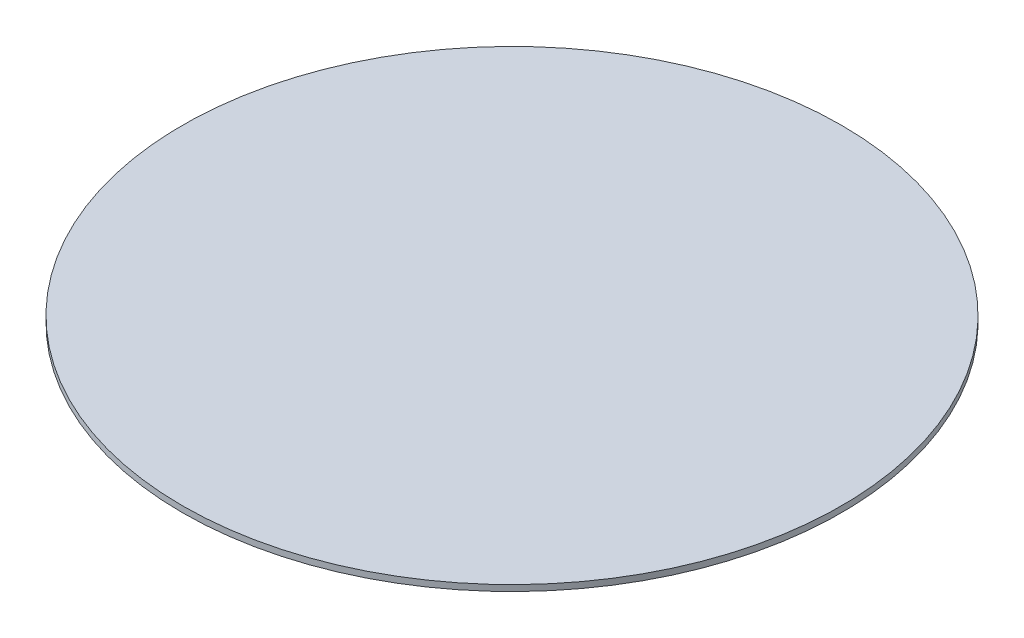
from build123d import *

# Parameters (mm, degrees)
ESQUISSE1_R        = 60
BOSS_EXTRU_1_DEPTH = 1.1


with BuildPart() as part:
    # Esquisse1 → Boss.-Extru.1 (new body)
    with BuildSketch(Plane(origin=(0, 129.098713563, 0), x_dir=(-1, 0, 0), z_dir=(0, 1, 0))):
        with Locations((322.943261647, -81.536826026)):
            Circle(ESQUISSE1_R)
    extrude(amount=BOSS_EXTRU_1_DEPTH)


solid = part.part
